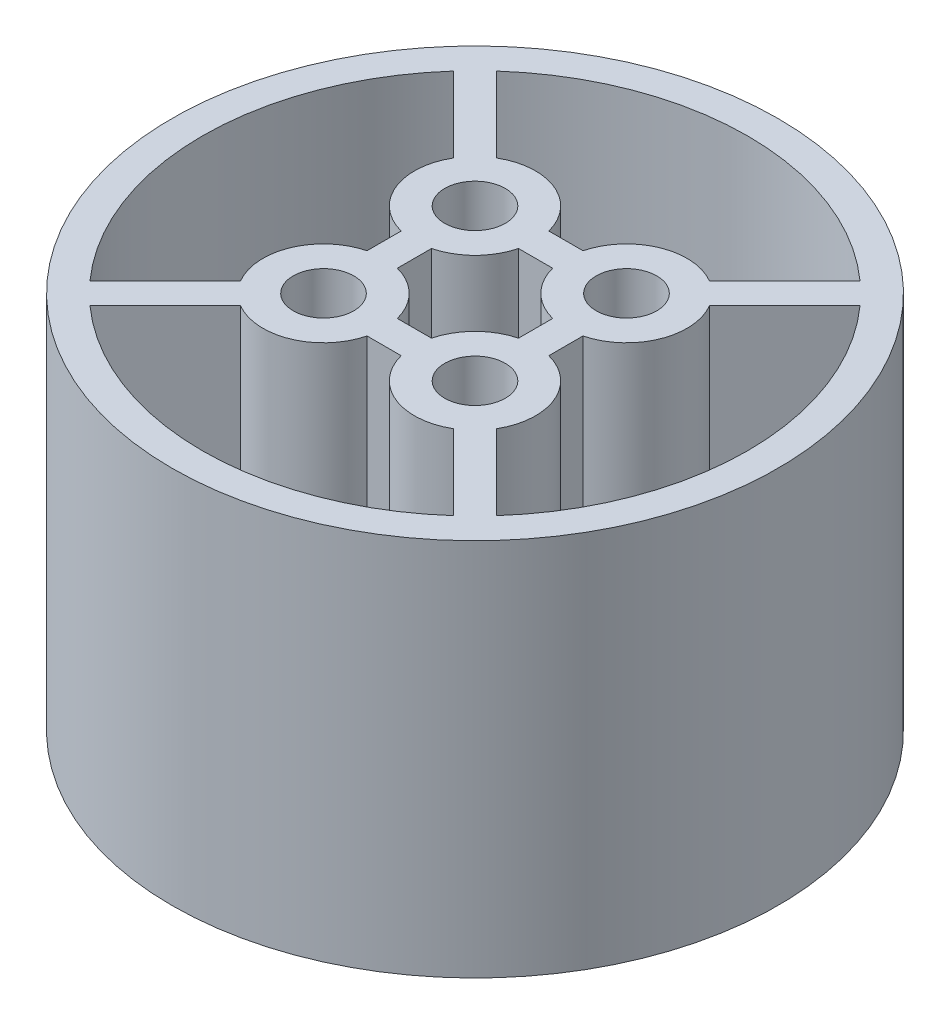
from build123d import *

# Parameters (mm, degrees)
SKETCH_2_R      = 20
SKETCH_2_R_2    = 2
EXTRUDE_1_DEPTH = 25


with BuildPart() as part:
    # 草图2 → 凸台-拉伸1 (new body)
    with BuildSketch(Plane(origin=(0, 0, 0), x_dir=(1, 0, 0), z_dir=(0, 1, 0))):
        Circle(SKETCH_2_R)
        with Locations((-5, 5)):
            Circle(SKETCH_2_R_2, mode=Mode.SUBTRACT)
        with Locations((5, 5)):
            Circle(SKETCH_2_R_2, mode=Mode.SUBTRACT)
        with Locations((5, -5)):
            Circle(SKETCH_2_R_2, mode=Mode.SUBTRACT)
        with Locations((-5, -5)):
            Circle(SKETCH_2_R_2, mode=Mode.SUBTRACT)
        with BuildLine():
            Line((-8.445719569, 7.031506006), (-13.415371808, 12.001158246))
            ThreePointArc((-13.415371808, 12.001158246), (-18, 0), (-13.415371808, -12.001158246))
            Line((-13.415371808, -12.001158246), (-8.445719569, -7.031506006))
            ThreePointArc((-8.445719569, -7.031506006), (-8.69551813, -3.469266271), (-6, -1.127016654))
            Line((-6, -1.127016654), (-6, 1.127016654))
            ThreePointArc((-6, 1.127016654), (-8.69551813, 3.469266271), (-8.445719569, 7.031506006))
        make_face(mode=Mode.SUBTRACT)
        with BuildLine():
            Line((-12.001158246, 13.415371808), (-7.031506006, 8.445719569))
            ThreePointArc((-7.031506006, 8.445719569), (-3.469266271, 8.69551813), (-1.127016654, 6))
            Line((-1.127016654, 6), (1.127016654, 6))
            ThreePointArc((1.127016654, 6), (3.469266271, 8.69551813), (7.031506006, 8.445719569))
            Line((7.031506006, 8.445719569), (12.001158246, 13.415371808))
            ThreePointArc((12.001158246, 13.415371808), (0, 18), (-12.001158246, 13.415371808))
        make_face(mode=Mode.SUBTRACT)
        with BuildLine():
            Line((13.415371808, 12.001158246), (8.445719569, 7.031506006))
            ThreePointArc((8.445719569, 7.031506006), (8.69551813, 3.469266271), (6, 1.127016654))
            Line((6, 1.127016654), (6, -1.127016654))
            ThreePointArc((6, -1.127016654), (8.69551813, -3.469266271), (8.445719569, -7.031506006))
            Line((8.445719569, -7.031506006), (13.415371808, -12.001158246))
            ThreePointArc((13.415371808, -12.001158246), (18, 0), (13.415371808, 12.001158246))
        make_face(mode=Mode.SUBTRACT)
        with BuildLine():
            Line((12.001158246, -13.415371808), (7.031506006, -8.445719569))
            ThreePointArc((7.031506006, -8.445719569), (3.469266271, -8.69551813), (1.127016654, -6))
            Line((1.127016654, -6), (-1.127016654, -6))
            ThreePointArc((-1.127016654, -6), (-3.469266271, -8.69551813), (-7.031506006, -8.445719569))
            Line((-7.031506006, -8.445719569), (-12.001158246, -13.415371808))
            ThreePointArc((-12.001158246, -13.415371808), (0, -18), (12.001158246, -13.415371808))
        make_face(mode=Mode.SUBTRACT)
        with BuildLine():
            Line((-1.127016654, 4), (1.127016654, 4))
            ThreePointArc((1.127016654, 4), (2.171572875, 2.171572875), (4, 1.127016654))
            Line((4, 1.127016654), (4, -1.127016654))
            ThreePointArc((4, -1.127016654), (2.171572875, -2.171572875), (1.127016654, -4))
            Line((1.127016654, -4), (-1.127016654, -4))
            ThreePointArc((-1.127016654, -4), (-2.171572875, -2.171572875), (-4, -1.127016654))
            Line((-4, -1.127016654), (-4, 1.127016654))
            ThreePointArc((-4, 1.127016654), (-2.171572875, 2.171572875), (-1.127016654, 4))
        make_face(mode=Mode.SUBTRACT)
    extrude(amount=EXTRUDE_1_DEPTH)


solid = part.part
